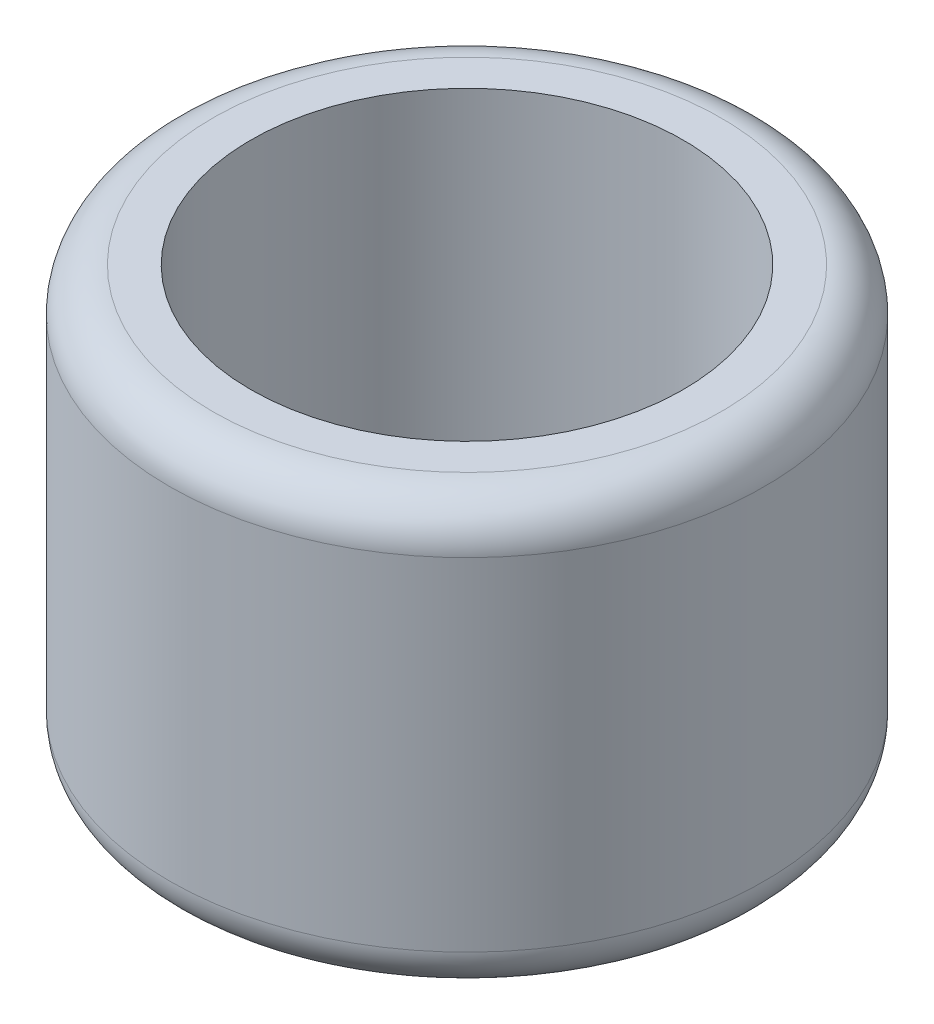
from build123d import *

# Parameters (mm, degrees)
SKETCH1_R           = 8.7376
SKETCH1_R_2         = 6.35
BOSS_EXTRUDE1_DEPTH = 6.2865
FILLET1_R           = 1.27


with BuildPart() as part:
    # Sketch1 → Boss-Extrude1 (new body, symmetric)
    with BuildSketch(Plane(origin=(0, 0, 0), x_dir=(1, 0, 0), z_dir=(0, 1, 0))):
        Circle(SKETCH1_R)
        Circle(SKETCH1_R_2, mode=Mode.SUBTRACT)
    extrude(amount=BOSS_EXTRUDE1_DEPTH, both=True)

    # Fillet1
    fillet1_edges = [part.edges().sort_by_distance(p)[0] for p in [
        (-8.7376, -6.2865, 0),
        (-8.7376, 6.2865, 0),
    ]]
    fillet(fillet1_edges, radius=FILLET1_R)


solid = part.part
